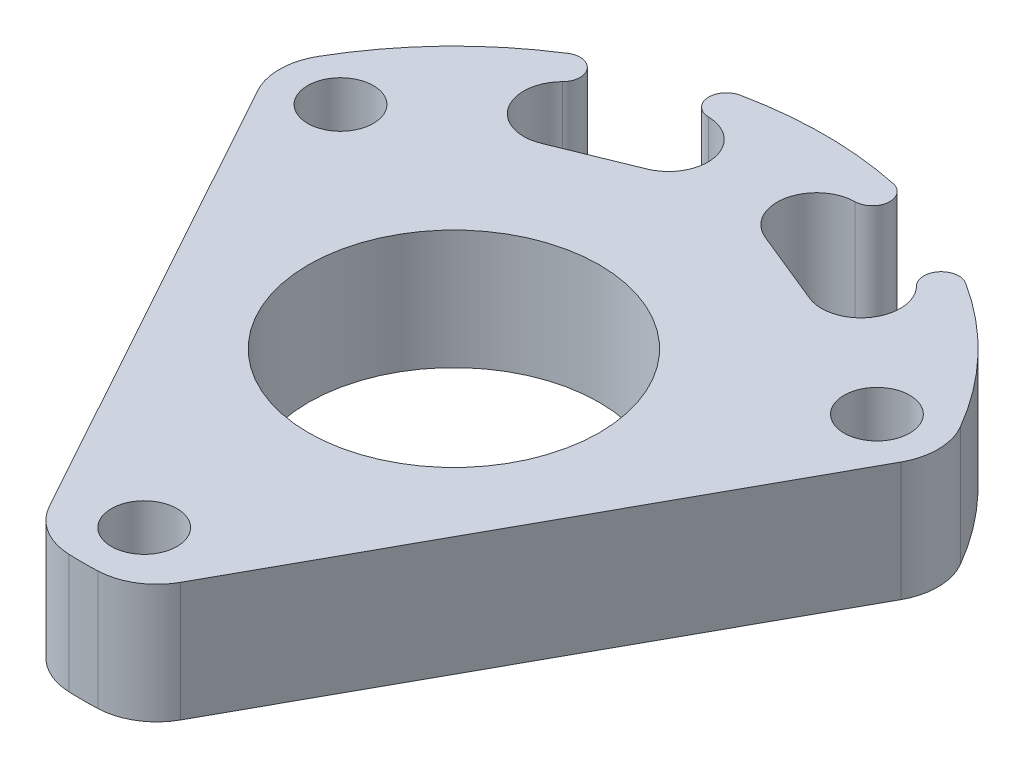
from build123d import *

# Parameters (mm, degrees)
SKETCH1_R           = 7.75
SKETCH1_R_2         = 1.75
BOSS_EXTRUDE1_DEPTH = 6.35
CUT_EXTRUDE1_DEPTH  = 7.35


with BuildPart() as part:
    # Sketch1 → Boss-Extrude1 (new body)
    with BuildSketch(Plane(origin=(0, 0, 0), x_dir=(1, 0, 0), z_dir=(0, 1, 0))):
        with BuildLine():
            Line((-17.135648679, 6.681090334), (-3.5, -18.055952583))
            ThreePointArc((-3.5, -18.055952583), (-2.361702731, -19.252086758), (-0.782543458, -19.734490765))
            ThreePointArc((-0.782543458, -19.734490765), (0, -19.75), (0.782543458, -19.734490765))
            ThreePointArc((0.782543458, -19.734490765), (2.361702731, -19.252086758), (3.5, -18.055952583))
            Line((3.5, -18.055952583), (17.135648679, 6.681090334))
            ThreePointArc((17.135648679, 6.681090334), (17.539259633, 8.282201146), (17.104001725, 9.875))
            ThreePointArc((17.104001725, 9.875), (0, 19.75), (-17.104001725, 9.875))
            ThreePointArc((-17.104001725, 9.875), (-17.539259633, 8.282201146), (-17.135648679, 6.681090334))
        make_face()
        with Locations(Location((0, 0, 0), (0, 0, 270))):  # turned: the seam where the file's is
            Circle(SKETCH1_R, mode=Mode.SUBTRACT)
        with Locations(Location((-14.289419162, 8.25, 0), (0, 0, 270))):  # turned: the seam where the file's is
            Circle(SKETCH1_R_2, mode=Mode.SUBTRACT)
        with Locations(Location((0, -16.5, 0), (0, 0, 270))):  # turned: the seam where the file's is
            Circle(SKETCH1_R_2, mode=Mode.SUBTRACT)
        with Locations(Location((14.289419162, 8.25, 0), (0, 0, 270))):  # turned: the seam where the file's is
            Circle(SKETCH1_R_2, mode=Mode.SUBTRACT)
    extrude(amount=BOSS_EXTRUDE1_DEPTH)

    # Sketch2 → Cut-Extrude1 (cut, through all)
    with BuildSketch(Plane(origin=(0, 6.35, 0), x_dir=(1, 0, 0), z_dir=(0, 1, 0))):
        with BuildLine():
            Line((3.147914252, 13.43813294), (7.146291664, 11.807764247))
            ThreePointArc((7.146291664, 11.807764247), (9.680193531, 12.584478285), (9.426519569, 15.222582318))
            ThreePointArc((9.426519569, 15.222582318), (9.362829603, 16.466865659), (10.592172309, 16.669384685))
            ThreePointArc((10.592172309, 16.669384685), (7.457105532, 18.288085659), (4.084045388, 19.323122762))
            ThreePointArc((4.084045388, 19.323122762), (4.821258852, 18.318725553), (3.905659686, 17.473754778))
            ThreePointArc((3.905659686, 17.473754778), (1.879612558, 15.765224297), (3.147914252, 13.43813294))
        make_face()
    cut_extrude1 = extrude(amount=-CUT_EXTRUDE1_DEPTH, mode=Mode.SUBTRACT)

    # Mirror1: Cut-Extrude1 across plane
    add(cut_extrude1.mirror(Plane(origin=(0, 0, 0), x_dir=(0, 0, 1), z_dir=(1, 0, 0))), mode=Mode.SUBTRACT)


solid = part.part
